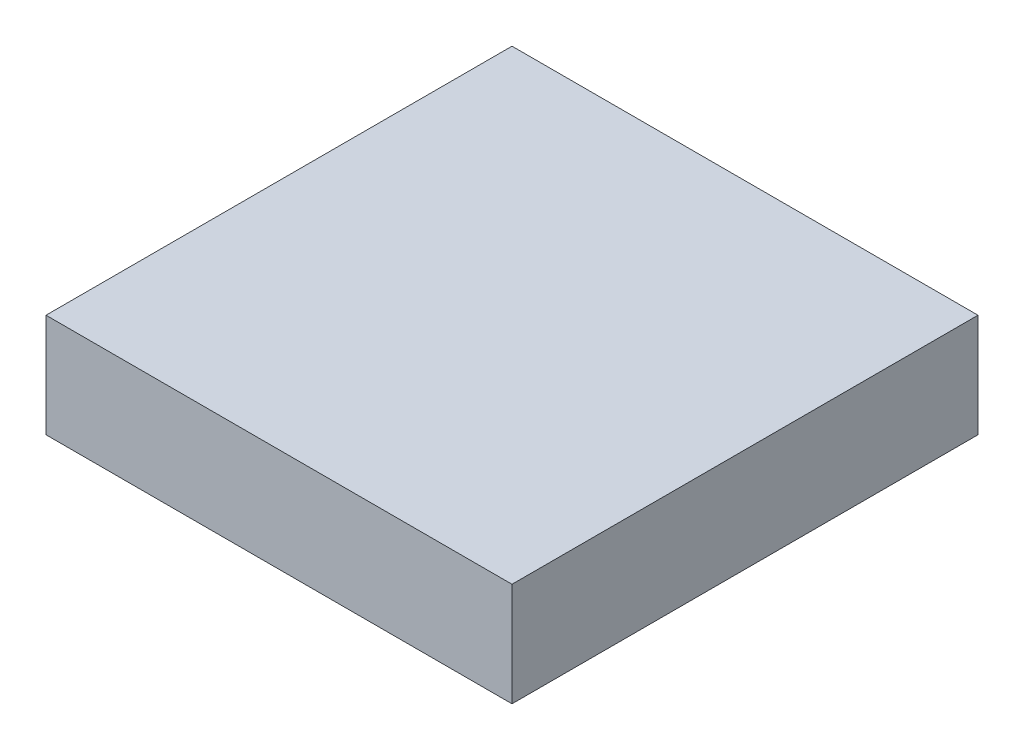
from build123d import *

# Parameters (mm, degrees)
SKETCH1_W      = 45
SKETCH1_H      = 45
EXTRUDE1_DEPTH = 10


with BuildPart() as part:
    # Sketch1 → Extrude1 (new body)
    with BuildSketch(Plane(origin=(0, 0, 0), x_dir=(1, 0, 0), z_dir=(0, 1, 0))):
        with Locations((-22.5, 22.5)):
            Rectangle(SKETCH1_W, SKETCH1_H)
    extrude(amount=EXTRUDE1_DEPTH)


solid = part.part
